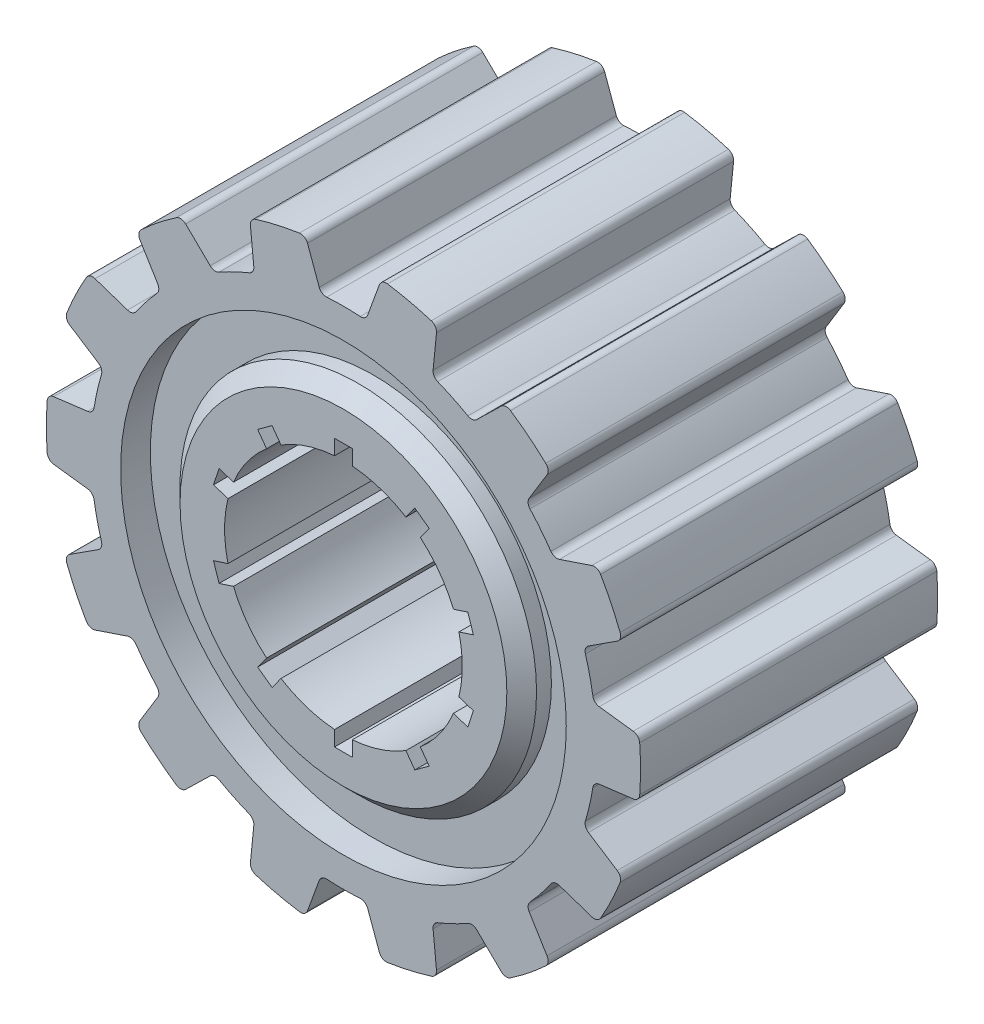
from build123d import *

# Parameters (mm, degrees)
SKETCH1_R           = 10
BOSS_EXTRUDE1_DEPTH = 10
CUT_EXTRUDE1_DEPTH  = 11
CIRPATTERN1_COUNT   = 14
CUT_EXTRUDE2_START  = -4
SKETCH3_R           = 7.5
SKETCH3_R_2         = 6
CUT_EXTRUDE2_DEPTH  = 2
CHAMFER1_SIZE       = 0.5
CHAMFER2_SIZE       = 0.5
FILLET1_R           = 0.25


with BuildPart() as part:
    # Sketch1 → Boss-Extrude1 (new body)
    with BuildSketch(Plane.XY):
        Circle(SKETCH1_R)
        with BuildLine():
            Line((2.402328537, 3.81691205), (2.101814002, 3.403289277))
            ThreePointArc((2.101814002, 3.403289277), (1.236067977, 3.804226065), (0.3, 3.988734135))
            Line((0.3, 3.988734135), (0.3, 4.5))
            Line((0.3, 4.5), (-0.3, 4.5))
            Line((-0.3, 4.5), (-0.3, 3.988734135))
            ThreePointArc((-0.3, 3.988734135), (-1.236067977, 3.804226065), (-2.101814002, 3.403289277))
            Line((-2.101814002, 3.403289277), (-2.402328537, 3.81691205))
            Line((-2.402328537, 3.81691205), (-2.887738734, 3.464240899))
            Line((-2.887738734, 3.464240899), (-2.587224198, 3.050618126))
            ThreePointArc((-2.587224198, 3.050618126), (-3.236067977, 2.351141009), (-3.700806493, 1.517903589))
            Line((-3.700806493, 1.517903589), (-4.187049225, 1.67589343))
            Line((-4.187049225, 1.67589343), (-4.372459422, 1.10525952))
            Line((-4.372459422, 1.10525952), (-3.886216689, 0.947269679))
            ThreePointArc((-3.886216689, 0.947269679), (-4, 0), (-3.886216689, -0.947269679))
            Line((-3.886216689, -0.947269679), (-4.372459422, -1.10525952))
            Line((-4.372459422, -1.10525952), (-4.187049225, -1.67589343))
            Line((-4.187049225, -1.67589343), (-3.700806493, -1.517903589))
            ThreePointArc((-3.700806493, -1.517903589), (-3.236067977, -2.351141009), (-2.587224198, -3.050618126))
            Line((-2.587224198, -3.050618126), (-2.887738734, -3.464240899))
            Line((-2.887738734, -3.464240899), (-2.402328537, -3.81691205))
            Line((-2.402328537, -3.81691205), (-2.101814002, -3.403289277))
            ThreePointArc((-2.101814002, -3.403289277), (-1.236067977, -3.804226065), (-0.3, -3.988734135))
            Line((-0.3, -3.988734135), (-0.3, -4.5))
            Line((-0.3, -4.5), (0.3, -4.5))
            Line((0.3, -4.5), (0.3, -3.988734135))
            ThreePointArc((0.3, -3.988734135), (1.236067977, -3.804226065), (2.101814002, -3.403289277))
            Line((2.101814002, -3.403289277), (2.402328537, -3.81691205))
            Line((2.402328537, -3.81691205), (2.887738734, -3.464240899))
            Line((2.887738734, -3.464240899), (2.587224198, -3.050618126))
            ThreePointArc((2.587224198, -3.050618126), (3.236067977, -2.351141009), (3.700806493, -1.517903589))
            Line((3.700806493, -1.517903589), (4.187049225, -1.67589343))
            Line((4.187049225, -1.67589343), (4.372459422, -1.10525952))
            Line((4.372459422, -1.10525952), (3.886216689, -0.947269679))
            ThreePointArc((3.886216689, -0.947269679), (4, 0), (3.886216689, 0.947269679))
            Line((3.886216689, 0.947269679), (4.372459422, 1.10525952))
            Line((4.372459422, 1.10525952), (4.187049225, 1.67589343))
            Line((4.187049225, 1.67589343), (3.700806493, 1.517903589))
            ThreePointArc((3.700806493, 1.517903589), (3.236067977, 2.351141009), (2.587224198, 3.050618126))
            Line((2.587224198, 3.050618126), (2.887738734, 3.464240899))
            Line((2.887738734, 3.464240899), (2.402328537, 3.81691205))
        make_face(mode=Mode.SUBTRACT)
    extrude(amount=BOSS_EXTRUDE1_DEPTH)

    # Sketch2 → Cut-Extrude1 (cut, through all)
    with BuildSketch(Plane.XY.offset(10)):
        with BuildLine():
            Line((0.75, 8.466847111), (1.278168411, 9.917977894))
            ThreePointArc((1.278168411, 9.917977894), (0, 10), (-1.278168411, 9.917977894))
            Line((-1.278168411, 9.917977894), (-0.75, 8.466847111))
            ThreePointArc((-0.75, 8.466847111), (0, 8.5), (0.75, 8.466847111))
        make_face()
    cut_extrude1 = extrude(amount=-CUT_EXTRUDE1_DEPTH, mode=Mode.SUBTRACT)

    # CirPattern1: Cut-Extrude1 ×14 about axis
    cirpattern1_axis = Axis((0, 0, 0), (0, 0, 1))
    for i in range(1, CIRPATTERN1_COUNT):
        add(cut_extrude1.rotate(cirpattern1_axis, i * 360 / CIRPATTERN1_COUNT), mode=Mode.SUBTRACT)

    # Sketch3 → Cut-Extrude2 (cut, through all)
    with BuildSketch(Plane.XY.offset(5).offset(CUT_EXTRUDE2_START)):
        Circle(SKETCH3_R)
        Circle(SKETCH3_R_2, mode=Mode.SUBTRACT)
    cut_extrude2 = extrude(amount=-CUT_EXTRUDE2_DEPTH, mode=Mode.SUBTRACT)

    # Chamfer1
    chamfer1_edges = [part.edges().sort_by_distance(p)[0] for p in [
        (-6, 0, 0),
    ]]
    chamfer(chamfer1_edges, length=CHAMFER1_SIZE)

    # Mirror2: Cut-Extrude2 across plane
    add(cut_extrude2.mirror(Plane.XY.offset(5)), mode=Mode.SUBTRACT)

    # Chamfer2
    chamfer2_edges = [part.edges().sort_by_distance(p)[0] for p in [
        (-6, 0, 10),
    ]]
    chamfer(chamfer2_edges, length=CHAMFER2_SIZE)

    # Fillet1
    fillet1_edges = [part.edges().sort_by_distance(p)[0] for p in [
        (1.278168411, 9.917977894, 5),
        (0.75, 8.466847111, 5),
        (-0.75, 8.466847111, 5),
        (-1.278168411, 9.917977894, 5),
        (-6.957262391, 7.183070376, 5),
        (-6.152030277, 5.865366439, 5),
        (-7.08726498, 4.692619216, 5),
        (-8.55111233, 5.184445768, 5),
        (-9.384894253, 3.453079765, 5),
        (-8.087674876, 2.615246661, 5),
        (-8.421456277, 1.152854793, 5),
        (-9.95373271, 0.960835643, 5),
        (-9.95373271, -0.960835643, 5),
        (-8.421456277, -1.152854793, 5),
        (-8.087674876, -2.615246661, 5),
        (-9.384894253, -3.453079765, 5),
        (-8.55111233, -5.184445768, 5),
        (-7.08726498, -4.692619216, 5),
        (-6.152030277, -5.865366439, 5),
        (-6.957262391, -7.183070376, 5),
        (-5.45483928, -8.381212826, 5),
        (-4.349353934, -7.302952852, 5),
        (-2.997900632, -7.953778461, 5),
        (-3.151659387, -9.490365805, 5),
        (-1.278168411, -9.917977894, 5),
        (-0.75, -8.466847111, 5),
        (0.75, -8.466847111, 5),
        (1.278168411, -9.917977894, 5),
        (3.151659387, -9.490365805, 5),
        (2.997900632, -7.953778461, 5),
        (4.349353934, -7.302952852, 5),
        (5.45483928, -8.381212826, 5),
        (6.957262391, -7.183070376, 5),
        (6.152030277, -5.865366439, 5),
        (7.08726498, -4.692619216, 5),
        (8.55111233, -5.184445768, 5),
        (9.384894253, -3.453079765, 5),
        (8.087674876, -2.615246661, 5),
        (8.421456277, -1.152854793, 5),
        (9.95373271, -0.960835643, 5),
        (9.95373271, 0.960835643, 5),
        (8.421456277, 1.152854793, 5),
        (8.087674876, 2.615246661, 5),
        (9.384894253, 3.453079765, 5),
        (8.55111233, 5.184445768, 5),
        (7.08726498, 4.692619216, 5),
        (6.152030277, 5.865366439, 5),
        (6.957262391, 7.183070376, 5),
        (5.45483928, 8.381212826, 5),
        (4.349353934, 7.302952852, 5),
        (2.997900632, 7.953778461, 5),
        (3.151659387, 9.490365805, 5),
        (-3.151659387, 9.490365805, 5),
        (-2.997900632, 7.953778461, 5),
        (-4.349353934, 7.302952852, 5),
        (-5.45483928, 8.381212826, 5),
    ]]
    fillet(fillet1_edges, radius=FILLET1_R)


solid = part.part
